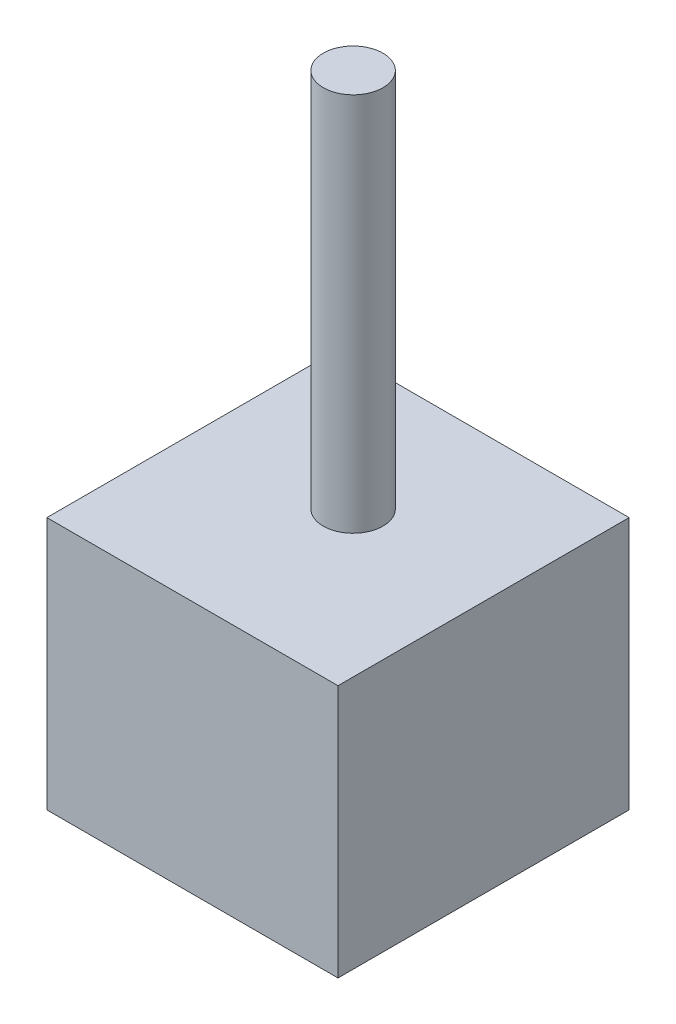
from build123d import *

# Parameters (mm, degrees)
SKETCH1_W           = 58.42
SKETCH1_H           = 58.42
BOSS_EXTRUDE1_DEPTH = 50.8
SKETCH2_R           = 6
BOSS_EXTRUDE2_DEPTH = 76.2


with BuildPart() as part:
    # Sketch1 → Boss-Extrude1 (new body)
    with BuildSketch(Plane(origin=(0, 0, 0), x_dir=(1, 0, 0), z_dir=(0, 1, 0))):
        with Locations((0, -3.030175439)):
            Rectangle(SKETCH1_W, SKETCH1_H)
    extrude(amount=BOSS_EXTRUDE1_DEPTH)

    # Sketch2 → Boss-Extrude2 (add)
    with BuildSketch(Plane(origin=(0, 50.8, 0), x_dir=(1, 0, 0), z_dir=(0, 1, 0))):
        Circle(SKETCH2_R)
    extrude(amount=BOSS_EXTRUDE2_DEPTH)


solid = part.part
